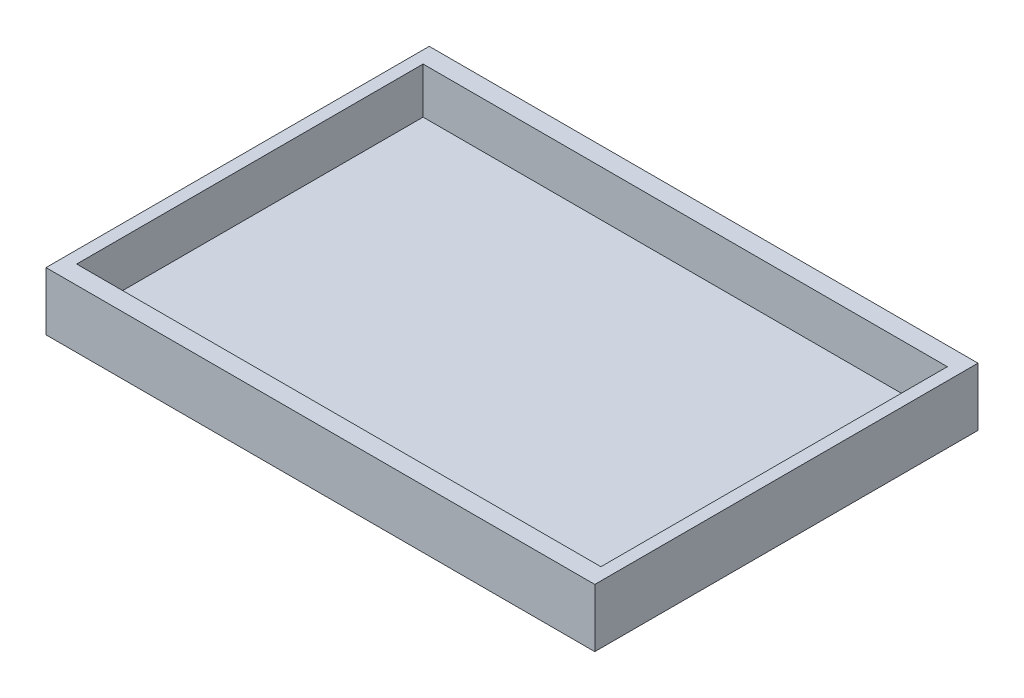
from build123d import *

# Parameters (mm, degrees)
SKETCH1_W           = 89.5
SKETCH1_H           = 62.5
BOSS_EXTRUDE1_DEPTH = 2
SKETCH7_W           = 89.5
SKETCH7_H           = 62.5
SKETCH7_W_2         = 85.5
SKETCH7_H_2         = 56.5
BOSS_EXTRUDE5_DEPTH = 7.5


with BuildPart() as part:
    # Sketch1 → Boss-Extrude1 (new body)
    with BuildSketch(Plane(origin=(0, 0, 0), x_dir=(1, 0, 0), z_dir=(0, 1, 0))):
        Rectangle(SKETCH1_W, SKETCH1_H)
    extrude(amount=BOSS_EXTRUDE1_DEPTH)

    # Sketch7 → Boss-Extrude5 (add)
    with BuildSketch(Plane(origin=(0, 2, 0), x_dir=(1, 0, 0), z_dir=(0, 1, 0))):
        Rectangle(SKETCH7_W, SKETCH7_H)
        Rectangle(SKETCH7_W_2, SKETCH7_H_2, mode=Mode.SUBTRACT)
    extrude(amount=BOSS_EXTRUDE5_DEPTH)


solid = part.part
